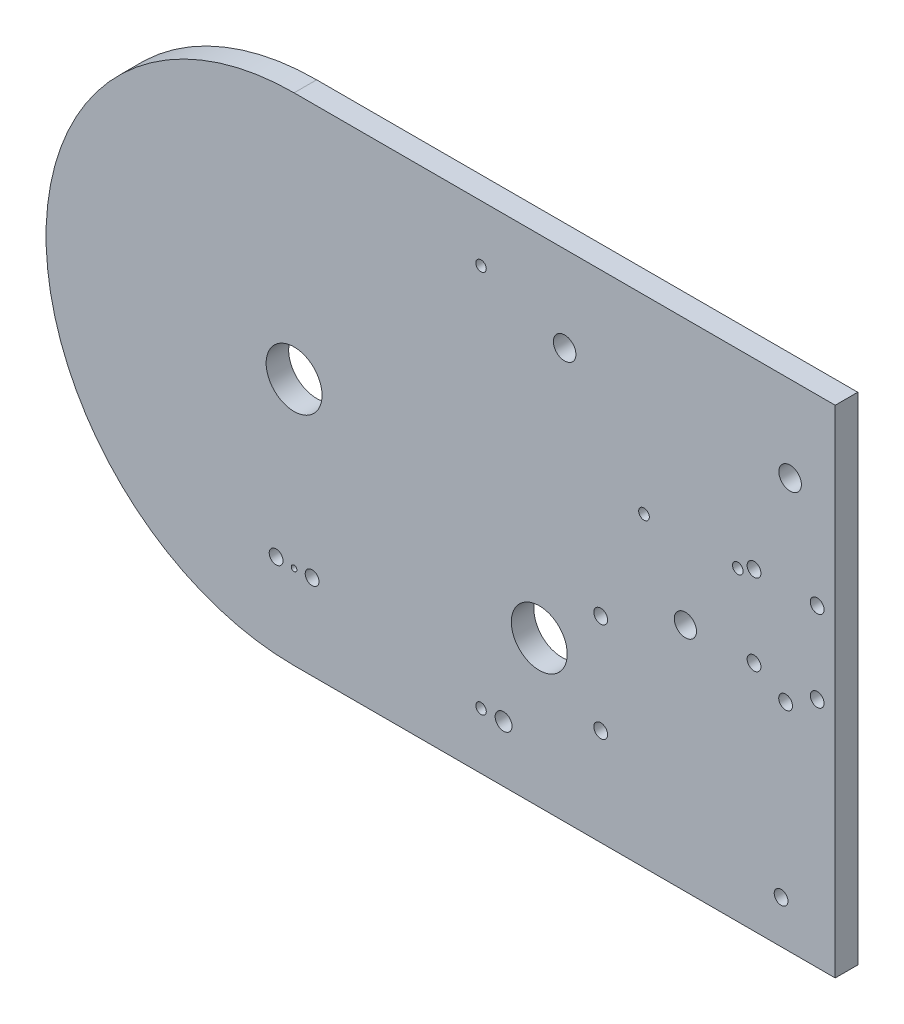
from build123d import *

# Parameters (mm, degrees)
SKETCH1_R                 = 7.874
BOSS_EXTRUDE1_DEPTH       = 6.35
CUT_EXTRUDE1_REACH        = 8.35
SKETCH2_R                 = 3.175
CUT_EXTRUDE6_REACH        = 8.35
SKETCH8_R                 = 3.127
F_4_CLEARANCE_HOLE1_D     = 2.9464
F_4_CLEARANCE_HOLE1_DEPTH = 6.35
F_4_CLEARANCE_HOLE2_D     = 3.8862
F_4_CLEARANCE_HOLE2_DEPTH = 6.35
CUT_EXTRUDE7_REACH        = 8.35
SKETCH13_R                = 0.79375
CUT_EXTRUDE8_REACH        = 8.35
SKETCH14_R                = 2.38125
F_2_CLEARANCE_HOLE1_D     = 2.9972
F_2_CLEARANCE_HOLE1_DEPTH = 6.35


with BuildPart() as part:
    # Sketch1 → Boss-Extrude1 (new body)
    with BuildSketch(Plane.XY):
        with BuildLine():
            Line((152.4, 69.85), (152.4, -69.85))
            Line((152.4, -69.85), (0, -69.85))
            ThreePointArc((0, -69.85), (-69.85, 0), (0, 69.85))
            Line((0, 69.85), (152.4, 69.85))
        make_face()
        with Locations((69.054102373, -28.60314574)):
            Circle(SKETCH1_R, mode=Mode.SUBTRACT)
        Circle(SKETCH1_R, mode=Mode.SUBTRACT)
    extrude(amount=BOSS_EXTRUDE1_DEPTH)

    # Sketch2 → Cut-Extrude1 (cut, up to next)
    with BuildSketch(Plane.XY.offset(6.35), mode=Mode.PRIVATE) as cut_extrude1_sk1:
        with Locations((76.2, 45.72)):
            Circle(SKETCH2_R)
    cut_extrude1_tool1 = extrude(cut_extrude1_sk1.sketch, amount=-CUT_EXTRUDE1_REACH, mode=Mode.PRIVATE) & part.part
    add(cut_extrude1_tool1.solids().sort_by_distance((76.2, 45.72, 6.35))[0], mode=Mode.SUBTRACT)
    # Sketch2 → Cut-Extrude1 (cut, up to next)
    with BuildSketch(Plane.XY.offset(6.35), mode=Mode.PRIVATE) as cut_extrude1_sk2:
        with Locations((139.7, 45.72)):
            Circle(SKETCH2_R)
    cut_extrude1_tool2 = extrude(cut_extrude1_sk2.sketch, amount=-CUT_EXTRUDE1_REACH, mode=Mode.PRIVATE) & part.part
    add(cut_extrude1_tool2.solids().sort_by_distance((139.7, 45.72, 6.35))[0], mode=Mode.SUBTRACT)

    # Sketch8 → Cut-Extrude6 (cut, up to next)
    with BuildSketch(Plane.XY.offset(6.35), mode=Mode.PRIVATE) as cut_extrude6_sk1:
        with Locations((110.206805808, -4.843621334)):
            Circle(SKETCH8_R)
    cut_extrude6_tool1 = extrude(cut_extrude6_sk1.sketch, amount=-CUT_EXTRUDE6_REACH, mode=Mode.PRIVATE) & part.part
    add(cut_extrude6_tool1.solids().sort_by_distance((110.206806, -4.843621, 6.35))[0], mode=Mode.SUBTRACT)

    # #4 Clearance Hole1
    with Locations(Plane.XY.offset(6.35)):
        with Locations((52.65432584, 53.975), (52.65432584, -53.975)):
            Hole(F_4_CLEARANCE_HOLE1_D / 2, depth=F_4_CLEARANCE_HOLE1_DEPTH)

    # #4 Clearance Hole2
    with Locations(Plane.XY.offset(6.35)):
        with Locations((129.54, 18.415), (147.32, 18.415), (147.32, -4.445), (129.54, -4.445), (138.43, -9.525), (86.36, -14.605), (86.36, -42.545), (137.16, -57.785), (5.073244581, -45.872975683), (-5.061355419, -45.872975683)):
            Hole(F_4_CLEARANCE_HOLE2_D / 2, depth=F_4_CLEARANCE_HOLE2_DEPTH)

    # Sketch13 → Cut-Extrude7 (cut, up to next)
    with BuildSketch(Plane.XY.offset(6.35), mode=Mode.PRIVATE) as cut_extrude7_sk1:
        with Locations((0.005944581, -46.140475683)):
            Circle(SKETCH13_R)
    cut_extrude7_tool1 = extrude(cut_extrude7_sk1.sketch, amount=-CUT_EXTRUDE7_REACH, mode=Mode.PRIVATE) & part.part
    add(cut_extrude7_tool1.solids().sort_by_distance((0.005945, -46.140476, 6.35))[0], mode=Mode.SUBTRACT)

    # Sketch14 → Cut-Extrude8 (cut, up to next)
    with BuildSketch(Plane.XY.offset(6.35), mode=Mode.PRIVATE) as cut_extrude8_sk1:
        with Locations((59.00432584, -53.975)):
            Circle(SKETCH14_R)
    cut_extrude8_tool1 = extrude(cut_extrude8_sk1.sketch, amount=-CUT_EXTRUDE8_REACH, mode=Mode.PRIVATE) & part.part
    add(cut_extrude8_tool1.solids().sort_by_distance((59.004326, -53.975, 6.35))[0], mode=Mode.SUBTRACT)

    # #2 Clearance Hole1
    with Locations(Plane.XY.offset(6.35)):
        with Locations((98.552, 16.383), (124.968, 16.383)):
            Hole(F_2_CLEARANCE_HOLE1_D / 2, depth=F_2_CLEARANCE_HOLE1_DEPTH)


solid = part.part
